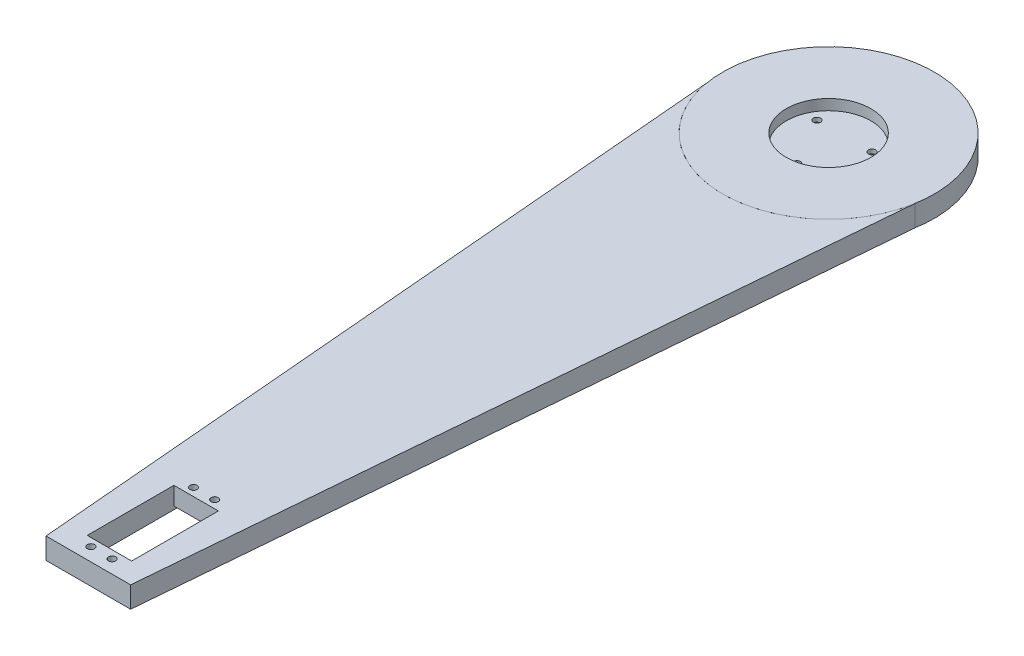
from build123d import *

# Parameters (mm, degrees)
SKETCH1_R           = 50
BOSS_EXTRUDE1_DEPTH = 10
SKETCH2_R           = 20
CUT_EXTRUDE1_DEPTH  = 5
CUT_EXTRUDE6_DEPTH  = 3
SKETCH8_R           = 1.7
CUT_EXTRUDE7_DEPTH  = 10
BOSS_EXTRUDE3_DEPTH = 10
SKETCH10_W          = 21
SKETCH10_H          = 41
CUT_EXTRUDE8_DEPTH  = 10
SKETCH11_W          = 21
SKETCH11_H          = 6.5
CUT_EXTRUDE9_DEPTH  = 1.5
SKETCH12_R          = 1.7
CUT_EXTRUDE10_DEPTH = 9
CUT_EXTRUDE11_DEPTH = 10


with BuildPart() as part:
    # Sketch1 → Boss-Extrude1 (new body)
    with BuildSketch(Plane(origin=(0, 0, 0), x_dir=(1, 0, 0), z_dir=(0, 1, 0))):
        Circle(SKETCH1_R)
    extrude(amount=BOSS_EXTRUDE1_DEPTH)

    # Sketch2 → Cut-Extrude1 (cut)
    with BuildSketch(Plane(origin=(0, 10, 0), x_dir=(1, 0, 0), z_dir=(0, 1, 0))):
        Circle(SKETCH2_R)
    extrude(amount=-CUT_EXTRUDE1_DEPTH, mode=Mode.SUBTRACT)

    # Sketch7 → Cut-Extrude6 (cut)
    with BuildSketch(Plane.XZ):
        with BuildLine():
            ThreePointArc((-2.85, 14.726761355), (0, 15), (2.85, 14.726761355))
            Line((2.85, 14.726761355), (2.85, 16.645448267))
            Line((2.85, 16.645448267), (0, 18.290896534))
            Line((0, 18.290896534), (-2.85, 16.645448267))
            Line((-2.85, 16.645448267), (-2.85, 14.726761355))
        make_face()
        with BuildLine():
            Line((2.85, 13.354551733), (2.85, 14.726761355))
            ThreePointArc((2.85, 14.726761355), (0, 15), (-2.85, 14.726761355))
            Line((-2.85, 14.726761355), (-2.85, 13.354551733))
            Line((-2.85, 13.354551733), (0, 11.709103466))
            Line((0, 11.709103466), (2.85, 13.354551733))
        make_face()
        Polygon((-12.990381057, -4.209103466), (-15.840381057, -5.854551733), (-15.840381057, -9.145448267), (-12.990381057, -10.790896534), (-10.140381057, -9.145448267), (-10.140381057, -5.854551733), align=None)
        Polygon((15.840381057, -5.854551733), (12.990381057, -4.209103466), (10.140381057, -5.854551733), (10.140381057, -9.145448267), (12.990381057, -10.790896534), (15.840381057, -9.145448267), align=None)
    extrude(amount=-CUT_EXTRUDE6_DEPTH, mode=Mode.SUBTRACT)

    # Sketch8 → Cut-Extrude7 (cut)
    with BuildSketch(Plane.XZ):
        with Locations((0, 15)):
            Circle(SKETCH8_R)
        with Locations((12.990381057, -7.5)):
            Circle(SKETCH8_R)
        with Locations((-12.990381057, -7.5)):
            Circle(SKETCH8_R)
    extrude(amount=-CUT_EXTRUDE7_DEPTH, mode=Mode.SUBTRACT)


with BuildPart() as body_2:
    # Sketch9 → Boss-Extrude3 (new body)
    with BuildSketch(Plane.XZ):
        with BuildLine():
            Line((-50, 350), (-50, 0))
            ThreePointArc((-50, 0), (0, 50), (50, 0))
            Line((50, 0), (50, 350))
            Line((50, 350), (-50, 350))
        make_face()
    extrude(amount=-BOSS_EXTRUDE3_DEPTH)

    # Sketch10 → Cut-Extrude8 (cut)
    with BuildSketch(Plane.XZ):
        with Locations((0, 319.5)):
            Rectangle(SKETCH10_W, SKETCH10_H)
    extrude(amount=-CUT_EXTRUDE8_DEPTH, mode=Mode.SUBTRACT)

    # Sketch11 → Cut-Extrude9 (cut)
    with BuildSketch(Plane.XZ):
        with Locations((0, 343.25)):
            Rectangle(SKETCH11_W, SKETCH11_H)
        with Locations((0, 295.75)):
            Rectangle(SKETCH11_W, SKETCH11_H)
    extrude(amount=-CUT_EXTRUDE9_DEPTH, mode=Mode.SUBTRACT)

    # Sketch12 → Cut-Extrude10 (cut)
    with BuildSketch(Plane.XZ.offset(-1.5)):
        with Locations((-5, 343.75)):
            Circle(SKETCH12_R)
        with Locations((5, 343.75)):
            Circle(SKETCH12_R)
        with Locations((-5, 295.25)):
            Circle(SKETCH12_R)
        with Locations((5, 295.25)):
            Circle(SKETCH12_R)
    extrude(amount=-CUT_EXTRUDE10_DEPTH, mode=Mode.SUBTRACT)

    # Sketch13 → Cut-Extrude11 (cut)
    with BuildSketch(Plane.XZ):
        with BuildLine():
            Line((-50, 350), (-50, 0))
            ThreePointArc((-50, 0), (-49.817332452, 4.270057067), (-49.270664506, 8.5089141))
            Line((-49.270664506, 8.5089141), (-20, 350))
            Line((-20, 350), (-50, 350))
        make_face()
        with BuildLine():
            Line((20, 350), (49.270664506, 8.5089141))
            ThreePointArc((49.270664506, 8.5089141), (49.817332452, 4.270057067), (50, 0))
            Line((50, 0), (50, 350))
            Line((50, 350), (20, 350))
        make_face()
    extrude(amount=-CUT_EXTRUDE11_DEPTH, mode=Mode.SUBTRACT)


solid = Compound([part.part, body_2.part])
